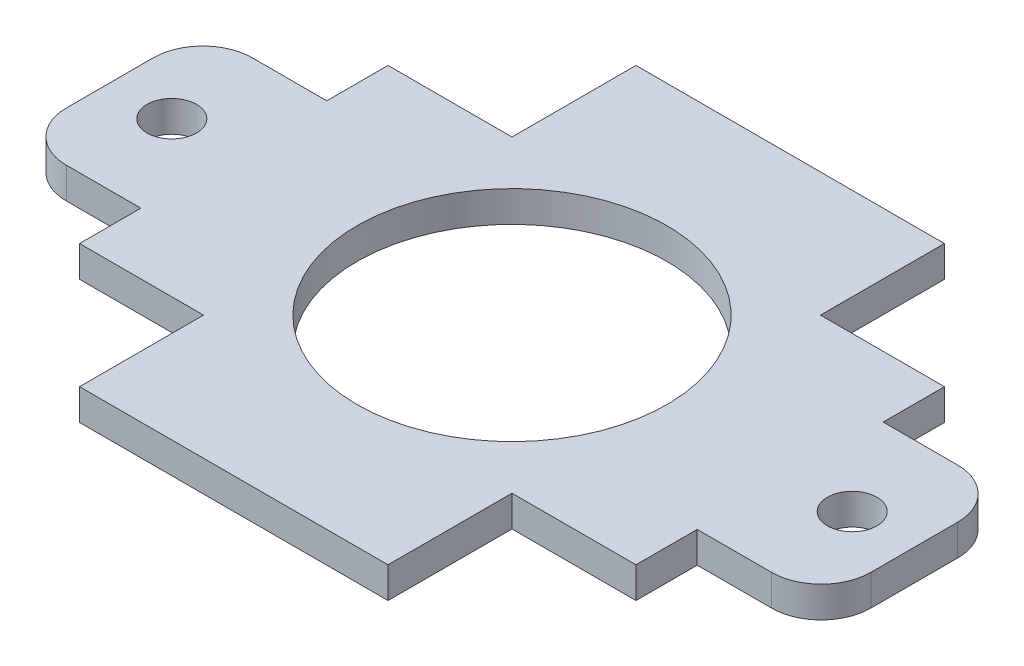
from build123d import *

# Parameters (mm, degrees)
SKETCH1_R           = 15.875
SKETCH1_R_2         = 2.54
BOSS_EXTRUDE1_DEPTH = 3.175


with BuildPart() as part:
    # Sketch1 → Boss-Extrude1 (new body)
    with BuildSketch(Plane(origin=(0, 0, 0), x_dir=(1, 0, 0), z_dir=(0, 1, 0))):
        with BuildLine():
            Line((-28.4999938, 15.7999938), (-28.4999938, 9.525))
            Line((-28.4999938, 9.525), (-36.1199938, 9.525))
            ThreePointArc((-36.1199938, 9.525), (-39.712096248, 8.037102448), (-41.1999938, 4.445))
            Line((-41.1999938, 4.445), (-41.1999938, -4.445))
            ThreePointArc((-41.1999938, -4.445), (-39.712096248, -8.037102448), (-36.1199938, -9.525))
            Line((-36.1199938, -9.525), (-28.4999938, -9.525))
            Line((-28.4999938, -9.525), (-28.4999938, -15.7999938))
            Line((-28.4999938, -15.7999938), (-15.7999938, -15.7999938))
            Line((-15.7999938, -15.7999938), (-15.7999938, -28.4999938))
            Line((-15.7999938, -28.4999938), (15.7999938, -28.4999938))
            Line((15.7999938, -28.4999938), (15.7999938, -15.7999938))
            Line((15.7999938, -15.7999938), (28.4999938, -15.7999938))
            Line((28.4999938, -15.7999938), (28.4999938, -9.525))
            Line((28.4999938, -9.525), (36.1199938, -9.525))
            ThreePointArc((36.1199938, -9.525), (39.712096248, -8.037102448), (41.1999938, -4.445))
            Line((41.1999938, -4.445), (41.1999938, 4.445))
            ThreePointArc((41.1999938, 4.445), (39.712096248, 8.037102448), (36.1199938, 9.525))
            Line((36.1199938, 9.525), (28.4999938, 9.525))
            Line((28.4999938, 9.525), (28.4999938, 15.7999938))
            Line((28.4999938, 15.7999938), (15.7999938, 15.7999938))
            Line((15.7999938, 15.7999938), (15.7999938, 28.4999938))
            Line((15.7999938, 28.4999938), (-15.7999938, 28.4999938))
            Line((-15.7999938, 28.4999938), (-15.7999938, 15.7999938))
            Line((-15.7999938, 15.7999938), (-28.4999938, 15.7999938))
        make_face()
        Circle(SKETCH1_R, mode=Mode.SUBTRACT)
        with Locations((-34.8499938, 0)):
            Circle(SKETCH1_R_2, mode=Mode.SUBTRACT)
        with Locations((34.8499938, 0)):
            Circle(SKETCH1_R_2, mode=Mode.SUBTRACT)
    extrude(amount=BOSS_EXTRUDE1_DEPTH)


solid = part.part
